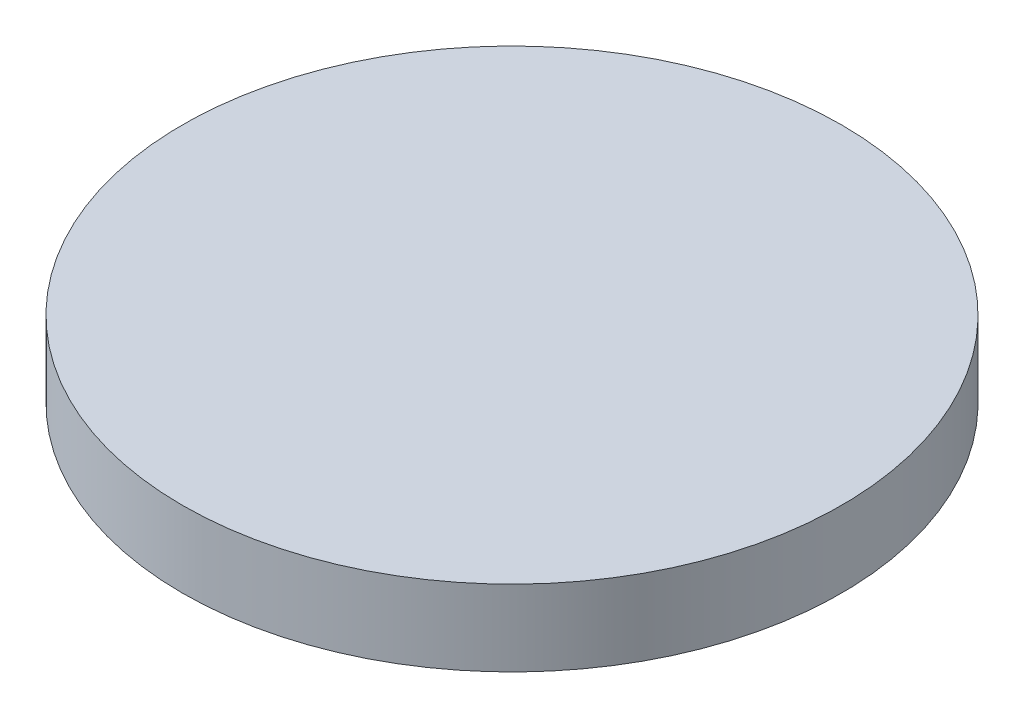
from build123d import *

# Parameters (mm, degrees)
SKETCH1_R           = 30
BOSS_EXTRUDE7_DEPTH = 5
SKETCH8_R           = 39
BOSS_EXTRUDE8_DEPTH = 9


with BuildPart() as part:
    # Sketch1 → Boss-Extrude7 (new body)
    with BuildSketch(Plane(origin=(0, 0, 0), x_dir=(1, 0, 0), z_dir=(0, 1, 0))):
        Circle(SKETCH1_R)
    extrude(amount=BOSS_EXTRUDE7_DEPTH)

    # Sketch8 → Boss-Extrude8 (add)
    with BuildSketch(Plane(origin=(0, 5, 0), x_dir=(1, 0, 0), z_dir=(0, 1, 0))):
        Circle(SKETCH8_R)
    extrude(amount=BOSS_EXTRUDE8_DEPTH)


solid = part.part
